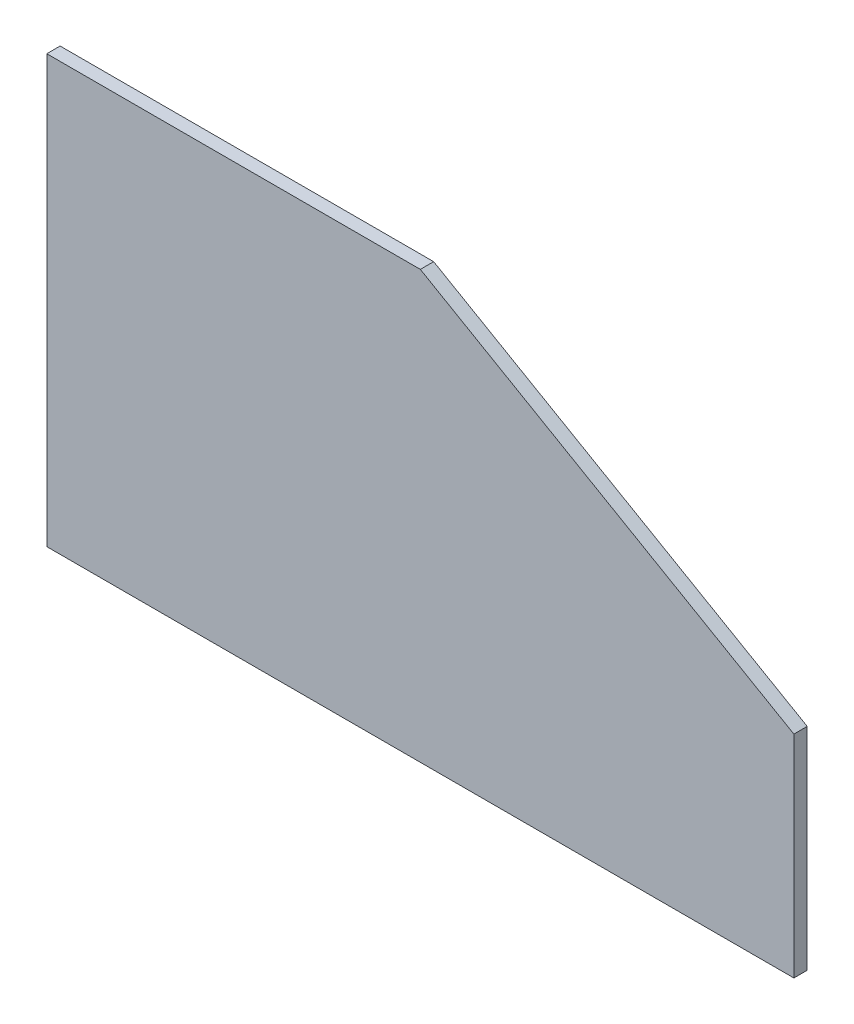
from build123d import *

# Parameters (mm, degrees)
BOSS_EXTRUDE1_DEPTH = 6.35


with BuildPart() as part:
    # Sketch1 → Boss-Extrude1 (new body)
    with BuildSketch(Plane.XY):
        Polygon((0, 0), (0, 203.2), (177.8, 203.2), (355.6, 100.547122138), (355.6, 0), align=None)
    extrude(amount=BOSS_EXTRUDE1_DEPTH)


solid = part.part
